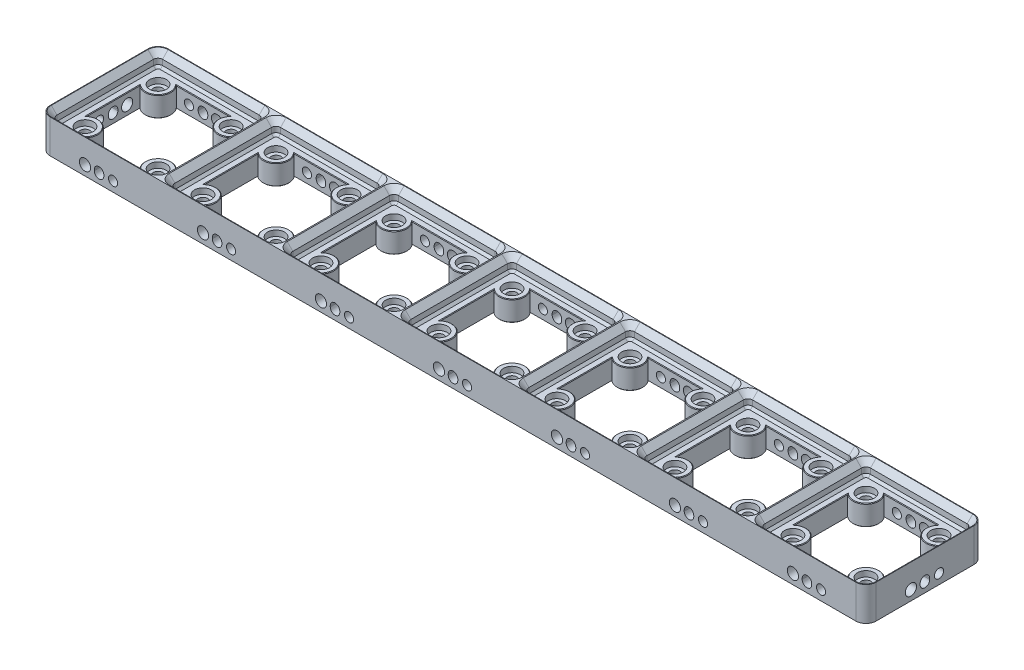
from build123d import *

# Parameters (mm, degrees)
SKETCH1_W                                     = 294
SKETCH1_H                                     = 42
MAIN_BODY_DEPTH                               = 6
GRID_CUT_OUT_DEPTH                            = 4.75
GRID_TOP_CHANFER_SIZE                         = 2
GRID_BOTTOM_CHANFER_SIZE                      = 0.8
SCREW_HOLES_D                                 = 3.4
SCREW_HOLES_CSINK_D                           = 6.72
SCREW_HOLES_CSINK_ANGLE                       = 90
SKETCH5_R                                     = 3
MAGNET_HOLES_DEPTH                            = 2
WEIGHT_REDUCTION_DEPTH                        = 149.669305844
WEIGHT_REDUCTION_CHAMFER_SIZE                 = 0.2
GRID_LENGTH_PATTERN_COUNT                     = 7
GRID_LENGTH_PATTERN_PITCH                     = 42
GRID_TOP_CHANFER_OF_GRID_LENGTH_PATTERN_SIZE  = 2
GRID_BOTTOM_CHANFER_OF_GRID_LENGTH_PATTE_SIZE = 0.8
WEIGHT_REDUCTION_CHAMFER_OF_GRID_LENGTH_SIZE  = 0.2
SKETCH29_R                                    = 1.63195
SKETCH29_R_2                                  = 2
LENGTH_HOLES_DEPTH                            = 10
WIDTH_START                                   = -10
SKETCH28_R                                    = 1.63195
SKETCH28_R_2                                  = 2
WIDTH_HOLES_DEPTH                             = 305.810108375
HOLE_LENGTH_PATTERN_COUNT                     = 7
HOLE_LENGTH_PATTERN_PITCH                     = 42
ROTATE_LENGTH_PATTERN_HOLES_COPY_1_SKETC_R    = 1.63195
ROTATE_LENGTH_PATTERN_HOLES_COPY_1_SKETC_R_2  = 2
ROTATE_LENGTH_PATTERN_HOLES_COPY_1_DEPTH      = 10
ROTATE_LENGTH_PATTERN_HOLES_COPY_2_SKETC_R    = 1.63195
ROTATE_LENGTH_PATTERN_HOLES_COPY_2_SKETC_R_2  = 2
ROTATE_LENGTH_PATTERN_HOLES_COPY_2_DEPTH      = 10
ROTATE_LENGTH_PATTERN_HOLES_COPY_3_SKETC_R    = 1.63195
ROTATE_LENGTH_PATTERN_HOLES_COPY_3_SKETC_R_2  = 2
ROTATE_LENGTH_PATTERN_HOLES_COPY_3_DEPTH      = 10
ROTATE_LENGTH_PATTERN_HOLES_COPY_4_SKETC_R    = 1.63195
ROTATE_LENGTH_PATTERN_HOLES_COPY_4_SKETC_R_2  = 2
ROTATE_LENGTH_PATTERN_HOLES_COPY_4_DEPTH      = 10
ROTATE_LENGTH_PATTERN_HOLES_COPY_5_SKETC_R    = 1.63195
ROTATE_LENGTH_PATTERN_HOLES_COPY_5_SKETC_R_2  = 2
ROTATE_LENGTH_PATTERN_HOLES_COPY_5_DEPTH      = 10
ROTATE_LENGTH_PATTERN_HOLES_COPY_6_SKETC_R    = 1.63195
ROTATE_LENGTH_PATTERN_HOLES_COPY_6_SKETC_R_2  = 2
ROTATE_LENGTH_PATTERN_HOLES_COPY_6_DEPTH      = 10
ROTATE_LENGTH_PATTERN_HOLES_COPY_7_SKETC_R    = 1.63195
ROTATE_LENGTH_PATTERN_HOLES_COPY_7_SKETC_R_2  = 2
ROTATE_LENGTH_PATTERN_HOLES_COPY_7_DEPTH      = 10
ROTATE_WIDTH_HOLES_COUNT                      = 2
FILLET_CORNERS_R                              = 3.6


with BuildPart() as part:
    # Sketch1 → MAIN BODY (new, symmetric)
    with BuildSketch(Plane(origin=(0, 0, 0), x_dir=(1, 0, 0), z_dir=(0, 1, 0))):
        Rectangle(SKETCH1_W, SKETCH1_H)
    extrude(amount=MAIN_BODY_DEPTH, both=True)

    # Sketch2 → GRID CUT OUT (cut)
    with BuildSketch(Plane(origin=(0, 6, 0), x_dir=(1, 0, 0), z_dir=(0, 1, 0))):
        with BuildLine():
            Line((143.2, -18.8), (108.8, -18.8))
            ThreePointArc((108.8, -18.8), (107.66862915, -18.33137085), (107.2, -17.2))
            Line((107.2, -17.2), (107.2, 17.2))
            ThreePointArc((107.2, 17.2), (107.66862915, 18.33137085), (108.8, 18.8))
            Line((108.8, 18.8), (143.2, 18.8))
            ThreePointArc((143.2, 18.8), (144.33137085, 18.33137085), (144.8, 17.2))
            Line((144.8, 17.2), (144.8, -17.2))
            ThreePointArc((144.8, -17.2), (144.33137085, -18.33137085), (143.2, -18.8))
        make_face()
    grid_cut_out = extrude(amount=-GRID_CUT_OUT_DEPTH, mode=Mode.SUBTRACT)

    # GRID TOP CHANFER
    grid_top_chanfer_edges = [part.edges().sort_by_distance(p)[0] for p in [
        (126, 6, 18.8),
        (144.33137085, 6, 18.33137085),
        (107.66862915, 6, 18.33137085),
        (144.8, 6, 0),
        (107.2, 6, 0),
        (144.33137085, 6, -18.33137085),
        (107.66862915, 6, -18.33137085),
        (126, 6, -18.8),
    ]]
    chamfer(grid_top_chanfer_edges, length=GRID_TOP_CHANFER_SIZE)

    # GRID BOTTOM CHANFER
    grid_bottom_chanfer_edges = [part.edges().sort_by_distance(p)[0] for p in [
        (126, 1.25, 18.8),
        (144.33137085, 1.25, 18.33137085),
        (107.66862915, 1.25, 18.33137085),
        (144.8, 1.25, 0),
        (107.2, 1.25, 0),
        (144.33137085, 1.25, -18.33137085),
        (107.66862915, 1.25, -18.33137085),
        (126, 1.25, -18.8),
    ]]
    chamfer(grid_bottom_chanfer_edges, length=GRID_BOTTOM_CHANFER_SIZE)

    # SCREW HOLES (through all)
    with Locations(Plane(origin=(0, -6, 0), x_dir=(-1, 0, 0), z_dir=(0, -1, 0))):
        with Locations((-113, -13), (-139, -13), (-139, 13), (-113, 13)):
            screw_holes = CounterSinkHole(SCREW_HOLES_D / 2, SCREW_HOLES_CSINK_D / 2, counter_sink_angle=SCREW_HOLES_CSINK_ANGLE)

    # Sketch5 → MAGNET HOLES (cut)
    with BuildSketch(Plane(origin=(0, 1.25, 0), x_dir=(1, 0, 0), z_dir=(0, 1, 0))):
        with Locations((113, -13)):
            Circle(SKETCH5_R)
        with Locations((113, 13)):
            Circle(SKETCH5_R)
        with Locations((139, 13)):
            Circle(SKETCH5_R)
        with Locations((139, -13)):
            Circle(SKETCH5_R)
    magnet_holes = extrude(amount=-MAGNET_HOLES_DEPTH, mode=Mode.SUBTRACT)

    # Sketch9 → WEIGHT REDUCTION (cut, through all)
    with BuildSketch(Plane(origin=(0, 1.25, 0), x_dir=(1, 0, 0), z_dir=(0, 1, 0))):
        with BuildLine():
            Line((116.487119155, -16), (135.512880845, -16))
            ThreePointArc((135.512880845, -16), (135.747308807, -9.747308807), (142, -9.512880845))
            Line((142, -9.512880845), (142, 9.512880845))
            ThreePointArc((142, 9.512880845), (135.747308807, 9.747308807), (135.512880845, 16))
            Line((135.512880845, 16), (116.487119155, 16))
            ThreePointArc((116.487119155, 16), (116.252691193, 9.747308807), (110, 9.512880845))
            Line((110, 9.512880845), (110, -9.512880845))
            ThreePointArc((110, -9.512880845), (116.252691193, -9.747308807), (116.487119155, -16))
        make_face()
    weight_reduction = extrude(amount=-WEIGHT_REDUCTION_DEPTH, mode=Mode.SUBTRACT)

    # WEIGHT REDUCTION CHAMFER
    weight_reduction_chamfer_edges = [part.edges().sort_by_distance(p)[0] for p in [
        (135.747308807, 1.25, 9.747308807),
        (142, 1.25, 0),
        (135.747308807, 1.25, -9.747308807),
        (126, 1.25, -16),
        (116.252691193, 1.25, -9.747308807),
        (110, 1.25, 0),
        (116.252691193, 1.25, 9.747308807),
        (126, 1.25, 16),
        (110, -6, 0),
        (116.252691193, -6, -9.747308807),
        (126, -6, -16),
        (135.747308807, -6, -9.747308807),
        (142, -6, 0),
        (135.747308807, -6, 9.747308807),
        (126, -6, 16),
        (116.252691193, -6, 9.747308807),
    ]]
    chamfer(weight_reduction_chamfer_edges, length=WEIGHT_REDUCTION_CHAMFER_SIZE)

    # GRID LENGTH PATTERN: GRID CUT OUT, SCREW HOLES, MAGNET HOLES, WEIGHT REDUCTION ×7
    with Locations(*[(-i * GRID_LENGTH_PATTERN_PITCH, 0, 0) for i in range(1, GRID_LENGTH_PATTERN_COUNT)]):
        add(grid_cut_out, mode=Mode.SUBTRACT)
        add(screw_holes, mode=Mode.SUBTRACT)
        add(magnet_holes, mode=Mode.SUBTRACT)
        add(weight_reduction, mode=Mode.SUBTRACT)

    # GRID TOP CHANFER of GRID LENGTH PATTERN
    grid_top_chanfer_of_grid_length_pattern_edges = [part.edges().sort_by_distance(p)[0] for p in [
        (84, 6, 18.8),
        (102.33137085, 6, 18.33137085),
        (65.66862915, 6, 18.33137085),
        (102.8, 6, 0),
        (65.2, 6, 0),
        (102.33137085, 6, -18.33137085),
        (65.66862915, 6, -18.33137085),
        (84, 6, -18.8),
        (42, 6, 18.8),
        (60.33137085, 6, 18.33137085),
        (23.66862915, 6, 18.33137085),
        (60.8, 6, 0),
        (23.2, 6, 0),
        (60.33137085, 6, -18.33137085),
        (23.66862915, 6, -18.33137085),
        (42, 6, -18.8),
        (0, 6, 18.8),
        (18.33137085, 6, 18.33137085),
        (-18.33137085, 6, 18.33137085),
        (18.8, 6, 0),
        (-18.8, 6, 0),
        (18.33137085, 6, -18.33137085),
        (-18.33137085, 6, -18.33137085),
        (0, 6, -18.8),
        (-42, 6, 18.8),
        (-23.66862915, 6, 18.33137085),
        (-60.33137085, 6, 18.33137085),
        (-23.2, 6, 0),
        (-60.8, 6, 0),
        (-23.66862915, 6, -18.33137085),
        (-60.33137085, 6, -18.33137085),
        (-42, 6, -18.8),
        (-84, 6, 18.8),
        (-65.66862915, 6, 18.33137085),
        (-102.33137085, 6, 18.33137085),
        (-65.2, 6, 0),
        (-102.8, 6, 0),
        (-65.66862915, 6, -18.33137085),
        (-102.33137085, 6, -18.33137085),
        (-84, 6, -18.8),
        (-126, 6, 18.8),
        (-107.66862915, 6, 18.33137085),
        (-144.33137085, 6, 18.33137085),
        (-107.2, 6, 0),
        (-144.8, 6, 0),
        (-107.66862915, 6, -18.33137085),
        (-144.33137085, 6, -18.33137085),
        (-126, 6, -18.8),
    ]]
    chamfer(grid_top_chanfer_of_grid_length_pattern_edges, length=GRID_TOP_CHANFER_OF_GRID_LENGTH_PATTERN_SIZE)

    # GRID BOTTOM CHANFER of GRID LENGTH PATTE
    grid_bottom_chanfer_of_grid_length_patte_edges = [part.edges().sort_by_distance(p)[0] for p in [
        (84, 1.25, 18.8),
        (102.33137085, 1.25, 18.33137085),
        (65.66862915, 1.25, 18.33137085),
        (102.8, 1.25, 0),
        (65.2, 1.25, 0),
        (102.33137085, 1.25, -18.33137085),
        (65.66862915, 1.25, -18.33137085),
        (84, 1.25, -18.8),
        (42, 1.25, 18.8),
        (60.33137085, 1.25, 18.33137085),
        (23.66862915, 1.25, 18.33137085),
        (60.8, 1.25, 0),
        (23.2, 1.25, 0),
        (60.33137085, 1.25, -18.33137085),
        (23.66862915, 1.25, -18.33137085),
        (42, 1.25, -18.8),
        (0, 1.25, 18.8),
        (18.33137085, 1.25, 18.33137085),
        (-18.33137085, 1.25, 18.33137085),
        (18.8, 1.25, 0),
        (-18.8, 1.25, 0),
        (18.33137085, 1.25, -18.33137085),
        (-18.33137085, 1.25, -18.33137085),
        (0, 1.25, -18.8),
        (-42, 1.25, 18.8),
        (-23.66862915, 1.25, 18.33137085),
        (-60.33137085, 1.25, 18.33137085),
        (-23.2, 1.25, 0),
        (-60.8, 1.25, 0),
        (-23.66862915, 1.25, -18.33137085),
        (-60.33137085, 1.25, -18.33137085),
        (-42, 1.25, -18.8),
        (-84, 1.25, 18.8),
        (-65.66862915, 1.25, 18.33137085),
        (-102.33137085, 1.25, 18.33137085),
        (-65.2, 1.25, 0),
        (-102.8, 1.25, 0),
        (-65.66862915, 1.25, -18.33137085),
        (-102.33137085, 1.25, -18.33137085),
        (-84, 1.25, -18.8),
        (-126, 1.25, 18.8),
        (-107.66862915, 1.25, 18.33137085),
        (-144.33137085, 1.25, 18.33137085),
        (-107.2, 1.25, 0),
        (-144.8, 1.25, 0),
        (-107.66862915, 1.25, -18.33137085),
        (-144.33137085, 1.25, -18.33137085),
        (-126, 1.25, -18.8),
    ]]
    chamfer(grid_bottom_chanfer_of_grid_length_patte_edges, length=GRID_BOTTOM_CHANFER_OF_GRID_LENGTH_PATTE_SIZE)

    # WEIGHT REDUCTION CHAMFER of GRID LENGTH
    weight_reduction_chamfer_of_grid_length_edges = [part.edges().sort_by_distance(p)[0] for p in [
        (93.747308807, 1.25, 9.747308807),
        (100, 1.25, 0),
        (93.747308807, 1.25, -9.747308807),
        (84, 1.25, -16),
        (74.252691193, 1.25, -9.747308807),
        (68, 1.25, 0),
        (74.252691193, 1.25, 9.747308807),
        (84, 1.25, 16),
        (68, -6, 0),
        (74.252691193, -6, -9.747308807),
        (84, -6, -16),
        (93.747308807, -6, -9.747308807),
        (100, -6, 0),
        (93.747308807, -6, 9.747308807),
        (84, -6, 16),
        (74.252691193, -6, 9.747308807),
        (51.747308807, 1.25, 9.747308807),
        (58, 1.25, 0),
        (51.747308807, 1.25, -9.747308807),
        (42, 1.25, -16),
        (32.252691193, 1.25, -9.747308807),
        (26, 1.25, 0),
        (32.252691193, 1.25, 9.747308807),
        (42, 1.25, 16),
        (26, -6, 0),
        (32.252691193, -6, -9.747308807),
        (42, -6, -16),
        (51.747308807, -6, -9.747308807),
        (58, -6, 0),
        (51.747308807, -6, 9.747308807),
        (42, -6, 16),
        (32.252691193, -6, 9.747308807),
        (9.747308807, 1.25, 9.747308807),
        (16, 1.25, 0),
        (9.747308807, 1.25, -9.747308807),
        (0, 1.25, -16),
        (-9.747308807, 1.25, -9.747308807),
        (-16, 1.25, 0),
        (-9.747308807, 1.25, 9.747308807),
        (0, 1.25, 16),
        (-16, -6, 0),
        (-9.747308807, -6, -9.747308807),
        (0, -6, -16),
        (9.747308807, -6, -9.747308807),
        (16, -6, 0),
        (9.747308807, -6, 9.747308807),
        (0, -6, 16),
        (-9.747308807, -6, 9.747308807),
        (-32.252691193, 1.25, 9.747308807),
        (-26, 1.25, 0),
        (-32.252691193, 1.25, -9.747308807),
        (-42, 1.25, -16),
        (-51.747308807, 1.25, -9.747308807),
        (-58, 1.25, 0),
        (-51.747308807, 1.25, 9.747308807),
        (-42, 1.25, 16),
        (-58, -6, 0),
        (-51.747308807, -6, -9.747308807),
        (-42, -6, -16),
        (-32.252691193, -6, -9.747308807),
        (-26, -6, 0),
        (-32.252691193, -6, 9.747308807),
        (-42, -6, 16),
        (-51.747308807, -6, 9.747308807),
        (-74.252691193, 1.25, 9.747308807),
        (-68, 1.25, 0),
        (-74.252691193, 1.25, -9.747308807),
        (-84, 1.25, -16),
        (-93.747308807, 1.25, -9.747308807),
        (-100, 1.25, 0),
        (-93.747308807, 1.25, 9.747308807),
        (-84, 1.25, 16),
        (-100, -6, 0),
        (-93.747308807, -6, -9.747308807),
        (-84, -6, -16),
        (-74.252691193, -6, -9.747308807),
        (-68, -6, 0),
        (-74.252691193, -6, 9.747308807),
        (-84, -6, 16),
        (-93.747308807, -6, 9.747308807),
        (-116.252691193, 1.25, 9.747308807),
        (-110, 1.25, 0),
        (-116.252691193, 1.25, -9.747308807),
        (-126, 1.25, -16),
        (-135.747308807, 1.25, -9.747308807),
        (-142, 1.25, 0),
        (-135.747308807, 1.25, 9.747308807),
        (-126, 1.25, 16),
        (-142, -6, 0),
        (-135.747308807, -6, -9.747308807),
        (-126, -6, -16),
        (-116.252691193, -6, -9.747308807),
        (-110, -6, 0),
        (-116.252691193, -6, 9.747308807),
        (-126, -6, 16),
        (-135.747308807, -6, 9.747308807),
    ]]
    chamfer(weight_reduction_chamfer_of_grid_length_edges, length=WEIGHT_REDUCTION_CHAMFER_OF_GRID_LENGTH_SIZE)

    # Sketch29 → LENGTH HOLES (cut)
    with BuildSketch(Plane.XY.offset(21)):
        with BuildLine():
            ThreePointArc((124.3, -2.7), (126, -4.4), (127.7, -2.7))
            Line((127.7, -2.7), (127.7, -2.3))
            ThreePointArc((127.7, -2.3), (126, -0.6), (124.3, -2.3))
            Line((124.3, -2.3), (124.3, -2.7))
        make_face()
        with Locations((131, -2.5)):
            Circle(SKETCH29_R)
        with Locations((121, -2.5)):
            Circle(SKETCH29_R_2)
    length_holes = extrude(amount=-LENGTH_HOLES_DEPTH, mode=Mode.SUBTRACT)

    # Sketch28 → WIDTH HOLES (cut)
    with BuildSketch(Plane(origin=(147, 0, 0), x_dir=(0, 0, -1), z_dir=(1, 0, 0)).offset(WIDTH_START)):
        with Locations((5, -2.5)):
            Circle(SKETCH28_R)
        with Locations((-5, -2.5)):
            Circle(SKETCH28_R_2)
        with BuildLine():
            Line((1.7, -2.7), (1.7, -2.3))
            ThreePointArc((1.7, -2.3), (0, -0.6), (-1.7, -2.3))
            Line((-1.7, -2.3), (-1.7, -2.7))
            ThreePointArc((-1.7, -2.7), (0, -4.4), (1.7, -2.7))
        make_face()
    width_holes = extrude(amount=WIDTH_HOLES_DEPTH, mode=Mode.SUBTRACT)

    # HOLE LENGTH PATTERN: LENGTH HOLES ×7
    with Locations(*[(-i * HOLE_LENGTH_PATTERN_PITCH, 0, 0) for i in range(1, HOLE_LENGTH_PATTERN_COUNT)]):
        add(length_holes, mode=Mode.SUBTRACT)

    # ROTATE LENGTH PATTERN HOLES copy 1 sketc → ROTATE LENGTH PATTERN HOLES copy 1 (cut)
    with BuildSketch(Plane(origin=(42, 0, -21), x_dir=(-1, 0, 0), z_dir=(0, 0, -1))):
        with BuildLine():
            ThreePointArc((124.3, -2.7), (126, -4.4), (127.7, -2.7))
            Line((127.7, -2.7), (127.7, -2.3))
            ThreePointArc((127.7, -2.3), (126, -0.6), (124.3, -2.3))
            Line((124.3, -2.3), (124.3, -2.7))
        make_face()
        with Locations((131, -2.5)):
            Circle(ROTATE_LENGTH_PATTERN_HOLES_COPY_1_SKETC_R)
        with Locations((121, -2.5)):
            Circle(ROTATE_LENGTH_PATTERN_HOLES_COPY_1_SKETC_R_2)
    extrude(amount=-ROTATE_LENGTH_PATTERN_HOLES_COPY_1_DEPTH, mode=Mode.SUBTRACT)

    # ROTATE LENGTH PATTERN HOLES copy 2 sketc → ROTATE LENGTH PATTERN HOLES copy 2 (cut)
    with BuildSketch(Plane(origin=(84, 0, -21), x_dir=(-1, 0, 0), z_dir=(0, 0, -1))):
        with BuildLine():
            ThreePointArc((124.3, -2.7), (126, -4.4), (127.7, -2.7))
            Line((127.7, -2.7), (127.7, -2.3))
            ThreePointArc((127.7, -2.3), (126, -0.6), (124.3, -2.3))
            Line((124.3, -2.3), (124.3, -2.7))
        make_face()
        with Locations((131, -2.5)):
            Circle(ROTATE_LENGTH_PATTERN_HOLES_COPY_2_SKETC_R)
        with Locations((121, -2.5)):
            Circle(ROTATE_LENGTH_PATTERN_HOLES_COPY_2_SKETC_R_2)
    extrude(amount=-ROTATE_LENGTH_PATTERN_HOLES_COPY_2_DEPTH, mode=Mode.SUBTRACT)

    # ROTATE LENGTH PATTERN HOLES copy 3 sketc → ROTATE LENGTH PATTERN HOLES copy 3 (cut)
    with BuildSketch(Plane(origin=(126, 0, -21), x_dir=(-1, 0, 0), z_dir=(0, 0, -1))):
        with BuildLine():
            ThreePointArc((124.3, -2.7), (126, -4.4), (127.7, -2.7))
            Line((127.7, -2.7), (127.7, -2.3))
            ThreePointArc((127.7, -2.3), (126, -0.6), (124.3, -2.3))
            Line((124.3, -2.3), (124.3, -2.7))
        make_face()
        with Locations((131, -2.5)):
            Circle(ROTATE_LENGTH_PATTERN_HOLES_COPY_3_SKETC_R)
        with Locations((121, -2.5)):
            Circle(ROTATE_LENGTH_PATTERN_HOLES_COPY_3_SKETC_R_2)
    extrude(amount=-ROTATE_LENGTH_PATTERN_HOLES_COPY_3_DEPTH, mode=Mode.SUBTRACT)

    # ROTATE LENGTH PATTERN HOLES copy 4 sketc → ROTATE LENGTH PATTERN HOLES copy 4 (cut)
    with BuildSketch(Plane(origin=(168, 0, -21), x_dir=(-1, 0, 0), z_dir=(0, 0, -1))):
        with BuildLine():
            ThreePointArc((124.3, -2.7), (126, -4.4), (127.7, -2.7))
            Line((127.7, -2.7), (127.7, -2.3))
            ThreePointArc((127.7, -2.3), (126, -0.6), (124.3, -2.3))
            Line((124.3, -2.3), (124.3, -2.7))
        make_face()
        with Locations((131, -2.5)):
            Circle(ROTATE_LENGTH_PATTERN_HOLES_COPY_4_SKETC_R)
        with Locations((121, -2.5)):
            Circle(ROTATE_LENGTH_PATTERN_HOLES_COPY_4_SKETC_R_2)
    extrude(amount=-ROTATE_LENGTH_PATTERN_HOLES_COPY_4_DEPTH, mode=Mode.SUBTRACT)

    # ROTATE LENGTH PATTERN HOLES copy 5 sketc → ROTATE LENGTH PATTERN HOLES copy 5 (cut)
    with BuildSketch(Plane(origin=(210, 0, -21), x_dir=(-1, 0, 0), z_dir=(0, 0, -1))):
        with BuildLine():
            ThreePointArc((124.3, -2.7), (126, -4.4), (127.7, -2.7))
            Line((127.7, -2.7), (127.7, -2.3))
            ThreePointArc((127.7, -2.3), (126, -0.6), (124.3, -2.3))
            Line((124.3, -2.3), (124.3, -2.7))
        make_face()
        with Locations((131, -2.5)):
            Circle(ROTATE_LENGTH_PATTERN_HOLES_COPY_5_SKETC_R)
        with Locations((121, -2.5)):
            Circle(ROTATE_LENGTH_PATTERN_HOLES_COPY_5_SKETC_R_2)
    extrude(amount=-ROTATE_LENGTH_PATTERN_HOLES_COPY_5_DEPTH, mode=Mode.SUBTRACT)

    # ROTATE LENGTH PATTERN HOLES copy 6 sketc → ROTATE LENGTH PATTERN HOLES copy 6 (cut)
    with BuildSketch(Plane(origin=(252, 0, -21), x_dir=(-1, 0, 0), z_dir=(0, 0, -1))):
        with BuildLine():
            ThreePointArc((124.3, -2.7), (126, -4.4), (127.7, -2.7))
            Line((127.7, -2.7), (127.7, -2.3))
            ThreePointArc((127.7, -2.3), (126, -0.6), (124.3, -2.3))
            Line((124.3, -2.3), (124.3, -2.7))
        make_face()
        with Locations((131, -2.5)):
            Circle(ROTATE_LENGTH_PATTERN_HOLES_COPY_6_SKETC_R)
        with Locations((121, -2.5)):
            Circle(ROTATE_LENGTH_PATTERN_HOLES_COPY_6_SKETC_R_2)
    extrude(amount=-ROTATE_LENGTH_PATTERN_HOLES_COPY_6_DEPTH, mode=Mode.SUBTRACT)

    # ROTATE LENGTH PATTERN HOLES copy 7 sketc → ROTATE LENGTH PATTERN HOLES copy 7 (cut)
    with BuildSketch(Plane(origin=(0, 0, -21), x_dir=(-1, 0, 0), z_dir=(0, 0, -1))):
        with BuildLine():
            ThreePointArc((124.3, -2.7), (126, -4.4), (127.7, -2.7))
            Line((127.7, -2.7), (127.7, -2.3))
            ThreePointArc((127.7, -2.3), (126, -0.6), (124.3, -2.3))
            Line((124.3, -2.3), (124.3, -2.7))
        make_face()
        with Locations((131, -2.5)):
            Circle(ROTATE_LENGTH_PATTERN_HOLES_COPY_7_SKETC_R)
        with Locations((121, -2.5)):
            Circle(ROTATE_LENGTH_PATTERN_HOLES_COPY_7_SKETC_R_2)
    extrude(amount=-ROTATE_LENGTH_PATTERN_HOLES_COPY_7_DEPTH, mode=Mode.SUBTRACT)

    # ROTATE WIDTH HOLES: WIDTH HOLES ×2 about axis
    rotate_width_holes_axis = Axis((0, -6.6, 0), (0, 1, 0))
    for i in range(1, ROTATE_WIDTH_HOLES_COUNT):
        add(width_holes.rotate(rotate_width_holes_axis, i * 360 / ROTATE_WIDTH_HOLES_COUNT), mode=Mode.SUBTRACT)

    # FILLET CORNERS
    fillet_corners_edges = [part.edges().sort_by_distance(p)[0] for p in [
        (-147, 0, -21),
        (147, 0, -21),
        (147, 0, 21),
        (-147, 0, 21),
    ]]
    fillet(fillet_corners_edges, radius=FILLET_CORNERS_R)


solid = part.part
